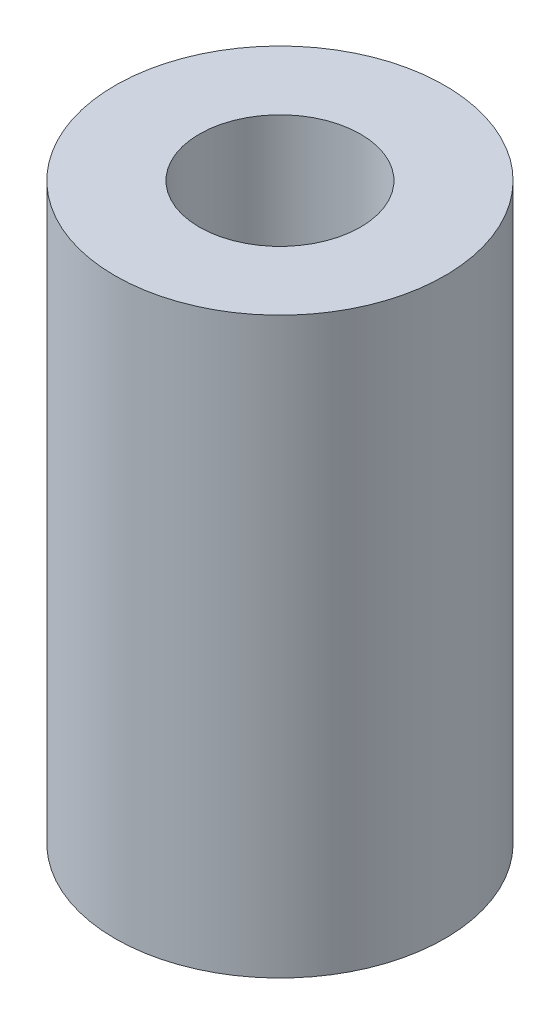
from build123d import *

# Parameters (mm, degrees)
SKETCH1_R           = 32.4612
SKETCH1_R_2         = 15.875
BOSS_EXTRUDE1_DEPTH = 113.03


with BuildPart() as part:
    # Sketch1 → Boss-Extrude1 (new body)
    with BuildSketch(Plane(origin=(0, 0, 0), x_dir=(1, 0, 0), z_dir=(0, 1, 0))):
        Circle(SKETCH1_R)
        Circle(SKETCH1_R_2, mode=Mode.SUBTRACT)
    extrude(amount=BOSS_EXTRUDE1_DEPTH)


solid = part.part
